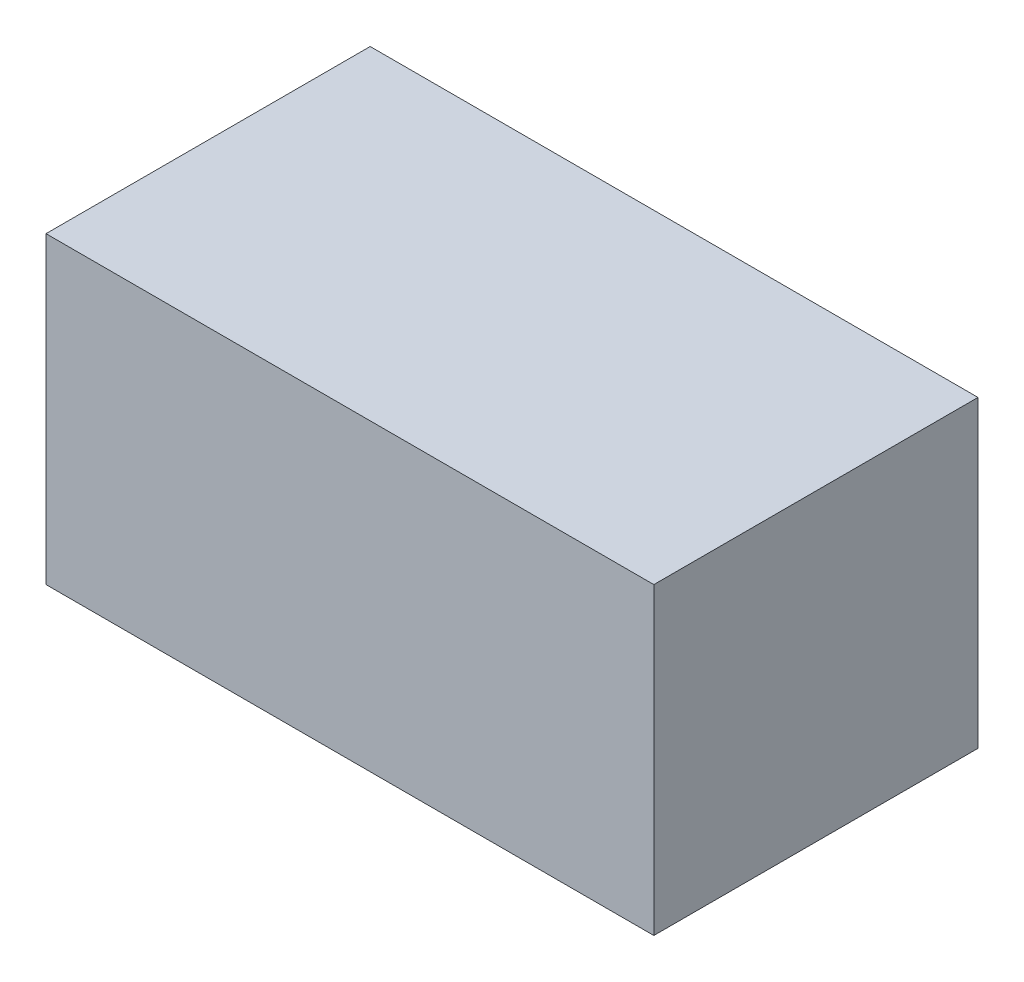
from build123d import *

# Parameters (mm, degrees)
SKETCH1_W      = 180
SKETCH1_H      = 96
EXTRUDE1_DEPTH = 90


with BuildPart() as part:
    # Sketch1 → Extrude1 (new body)
    with BuildSketch(Plane(origin=(0, 0, 0), x_dir=(1, 0, 0), z_dir=(0, 1, 0))):
        with Locations((-90, 48)):
            Rectangle(SKETCH1_W, SKETCH1_H)
    extrude(amount=EXTRUDE1_DEPTH)


solid = part.part
